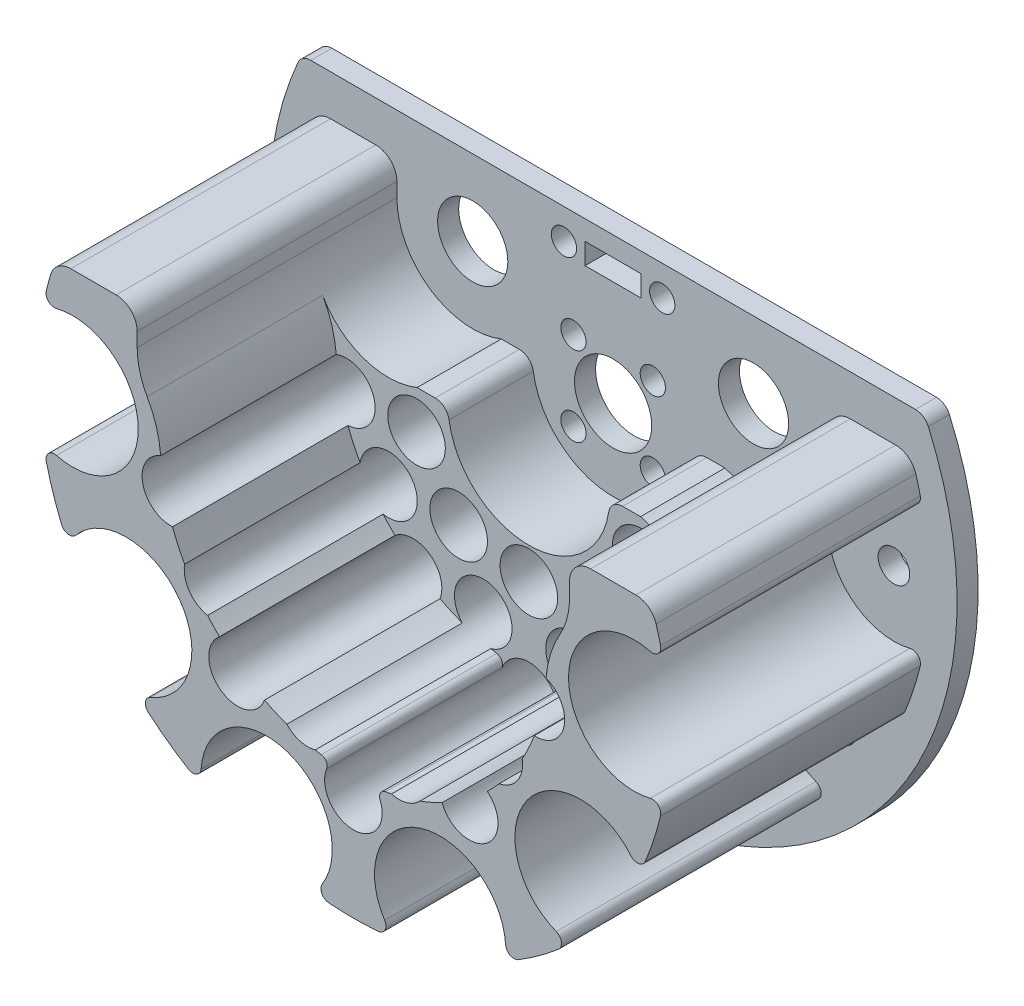
from build123d import *

# Parameters (mm, degrees)
EXTRUDE_1_DEPTH             = 25
EXTRUDE_2_DEPTH             = 12
EXTRUDE_3_DEPTH             = 3
SKETCH_4_W                  = 8
SKETCH_4_H                  = 3
CUT_EXTRUDE_1_DEPTH         = 41
SKETCH_5_W                  = 4.1
SKETCH_5_H                  = 39
SKETCH_6_W                  = 4.1
SKETCH_6_H                  = 39
SKETCH_7_W                  = 4.1
SKETCH_7_H                  = 39
SKETCH_8_W                  = 4.1
SKETCH_8_H                  = 39
SKETCH_9_W                  = 4.1
SKETCH_9_H                  = 39
SKETCH_10_W                 = 4.1
SKETCH_10_H                 = 39
HOLE_WIZARD_8_2_8_2_1_D     = 8.2
HOLE_WIZARD_8_2_8_2_1_DEPTH = 39
HOLE_WIZARD_8_2_8_2_2_D     = 8.2
HOLE_WIZARD_8_2_8_2_2_DEPTH = 14
HOLE_WIZARD_8_2_8_2_3_D     = 8.2
HOLE_WIZARD_8_2_8_2_3_DEPTH = 40
HOLE_WIZARD_4_5_4_5_1_D     = 4.5
HOLE_WIZARD_4_5_4_5_1_DEPTH = 40
HOLE_WIZARD_11_0_11_1_D     = 11
HOLE_WIZARD_11_0_11_1_DEPTH = 40
HOLE_WIZARD_10_0_10_1_D     = 10
HOLE_WIZARD_10_0_10_1_DEPTH = 40
HOLE_WIZARD_3_6_3_6_1_D     = 3.6
HOLE_WIZARD_3_6_3_6_1_DEPTH = 40
FILLET_1_R                  = 1
FILLET_2_R                  = 2
FILLET_3_R                  = 3


with BuildPart() as part:
    # 草图1 → 凸台-拉伸1 (new body)
    with BuildSketch(Plane.XY.offset(40)):
        with BuildLine():
            Line((-30.8, 160), (-30.8, 165))
            Line((-30.8, 165), (-42.426406871, 165))
            ThreePointArc((-42.426406871, 165), (-43.14973204, 162.7710855), (-43.756046661, 160.507539227))
            ThreePointArc((-43.756046661, 160.507539227), (-43.432520931, 159.373616076), (-42.294710456, 159.064039051))
            ThreePointArc((-42.294710456, 159.064039051), (-30.65, 150), (-42.294710456, 140.935960949))
            ThreePointArc((-42.294710456, 140.935960949), (-43.432520931, 140.626383924), (-43.756046661, 139.492460773))
            ThreePointArc((-43.756046661, 139.492460773), (-42.797543233, 136.094235253), (-41.575561951, 132.781618878))
            ThreePointArc((-41.575561951, 132.781618878), (-40.647320832, 132.054419431), (-39.544848012, 132.472754574))
            ThreePointArc((-39.544848012, 132.472754574), (-24.796370878, 131.984382017), (-28.889431051, 117.806831314))
            ThreePointArc((-28.889431051, 117.806831314), (-29.627974251, 116.887590023), (-29.22320876, 115.78006327))
            ThreePointArc((-29.22320876, 115.78006327), (-26.450336353, 113.594235253), (-23.514625677, 111.632534886))
            ThreePointArc((-23.514625677, 111.632534886), (-22.336225726, 111.589824616), (-21.690197707, 112.57628212))
            ThreePointArc((-21.690197707, 112.57628212), (-9.471370878, 120.850117776), (-4.449370899, 106.974397911))
            ThreePointArc((-4.449370899, 106.974397911), (-4.506548426, 105.796611284), (-3.528098373, 105.138518506))
            ThreePointArc((-3.528098373, 105.138518506), (0, 105), (3.528098373, 105.138518506))
            ThreePointArc((3.528098373, 105.138518506), (4.506548426, 105.796611284), (4.449370899, 106.974397911))
            ThreePointArc((4.449370899, 106.974397911), (9.471370878, 120.850117776), (21.690197707, 112.57628212))
            ThreePointArc((21.690197707, 112.57628212), (22.336225726, 111.589824616), (23.514625677, 111.632534886))
            ThreePointArc((23.514625677, 111.632534886), (26.450336353, 113.594235253), (29.22320876, 115.78006327))
            ThreePointArc((29.22320876, 115.78006327), (29.627974251, 116.887590023), (28.889431051, 117.806831314))
            ThreePointArc((28.889431051, 117.806831314), (24.796370878, 131.984382017), (39.544848012, 132.472754574))
            ThreePointArc((39.544848012, 132.472754574), (40.647320832, 132.054419431), (41.575561951, 132.781618878))
            ThreePointArc((41.575561951, 132.781618878), (42.797543233, 136.094235253), (43.756046661, 139.492460773))
            ThreePointArc((43.756046661, 139.492460773), (43.432520931, 140.626383924), (42.294710456, 140.935960949))
            ThreePointArc((42.294710456, 140.935960949), (30.65, 150), (42.294710456, 159.064039051))
            ThreePointArc((42.294710456, 159.064039051), (43.432520931, 159.373616076), (43.756046661, 160.507539227))
            ThreePointArc((43.756046661, 160.507539227), (43.14973204, 162.7710855), (42.426406871, 165))
            Line((42.426406871, 165), (30.8, 165))
            Line((30.8, 165), (30.8, 160))
            ThreePointArc((30.8, 160), (30.438925132, 157.230732571), (29.379844057, 154.646634192))
            ThreePointArc((29.379844057, 154.646634192), (28.022973878, 151.464418622), (27.431201542, 148.055988174))
            ThreePointArc((27.431201542, 148.055988174), (0, 122.5), (-27.431201542, 148.055988174))
            ThreePointArc((-27.431201542, 148.055988174), (-28.022973878, 151.464418622), (-29.379844057, 154.646634192))
            ThreePointArc((-29.379844057, 154.646634192), (-30.438925132, 157.230732571), (-30.8, 160))
        make_face()
    extrude(amount=-EXTRUDE_1_DEPTH)

    # 草图2 → 凸台-拉伸2 (add)
    with BuildSketch(Plane(origin=(0, 0, 15), x_dir=(-1, 0, 0), z_dir=(0, 0, -1))):
        with BuildLine():
            Line((-42.426406871, 165), (-30.8, 165))
            Line((-30.8, 165), (-30.8, 160))
            ThreePointArc((-30.8, 160), (-26.024303752, 151.036308556), (-15.920784389, 150))
            Line((-15.920784389, 150), (-11.5, 150))
            ThreePointArc((-11.5, 150), (0, 138.5), (11.5, 150))
            Line((11.5, 150), (15.920784389, 150))
            ThreePointArc((15.920784389, 150), (26.024303752, 151.036308556), (30.8, 160))
            Line((30.8, 160), (30.8, 165))
            Line((30.8, 165), (42.426406871, 165))
            ThreePointArc((42.426406871, 165), (43.14973204, 162.7710855), (43.756046661, 160.507539227))
            ThreePointArc((43.756046661, 160.507539227), (43.432520931, 159.373616076), (42.294710456, 159.064039051))
            ThreePointArc((42.294710456, 159.064039051), (30.65, 150), (42.294710456, 140.935960949))
            ThreePointArc((42.294710456, 140.935960949), (43.432520931, 140.626383924), (43.756046661, 139.492460773))
            ThreePointArc((43.756046661, 139.492460773), (42.797543233, 136.094235253), (41.575561951, 132.781618878))
            ThreePointArc((41.575561951, 132.781618878), (40.647320832, 132.054419431), (39.544848012, 132.472754574))
            ThreePointArc((39.544848012, 132.472754574), (24.796370878, 131.984382017), (28.889431051, 117.806831314))
            ThreePointArc((28.889431051, 117.806831314), (29.627974251, 116.887590023), (29.22320876, 115.78006327))
            ThreePointArc((29.22320876, 115.78006327), (26.450336353, 113.594235253), (23.514625677, 111.632534886))
            ThreePointArc((23.514625677, 111.632534886), (22.336225726, 111.589824616), (21.690197707, 112.57628212))
            ThreePointArc((21.690197707, 112.57628212), (9.471370878, 120.850117776), (4.449370899, 106.974397911))
            ThreePointArc((4.449370899, 106.974397911), (4.506548426, 105.796611284), (3.528098373, 105.138518506))
            ThreePointArc((3.528098373, 105.138518506), (0, 105), (-3.528098373, 105.138518506))
            ThreePointArc((-3.528098373, 105.138518506), (-4.506548426, 105.796611284), (-4.449370899, 106.974397911))
            ThreePointArc((-4.449370899, 106.974397911), (-9.471370878, 120.850117776), (-21.690197707, 112.57628212))
            ThreePointArc((-21.690197707, 112.57628212), (-22.336225726, 111.589824616), (-23.514625677, 111.632534886))
            ThreePointArc((-23.514625677, 111.632534886), (-26.450336353, 113.594235253), (-29.22320876, 115.78006327))
            ThreePointArc((-29.22320876, 115.78006327), (-29.627974251, 116.887590023), (-28.889431051, 117.806831314))
            ThreePointArc((-28.889431051, 117.806831314), (-24.796370878, 131.984382017), (-39.544848012, 132.472754574))
            ThreePointArc((-39.544848012, 132.472754574), (-40.647320832, 132.054419431), (-41.575561951, 132.781618878))
            ThreePointArc((-41.575561951, 132.781618878), (-42.797543233, 136.094235253), (-43.756046661, 139.492460773))
            ThreePointArc((-43.756046661, 139.492460773), (-43.432520931, 140.626383924), (-42.294710456, 140.935960949))
            ThreePointArc((-42.294710456, 140.935960949), (-30.65, 150), (-42.294710456, 159.064039051))
            ThreePointArc((-42.294710456, 159.064039051), (-43.432520931, 159.373616076), (-43.756046661, 160.507539227))
            ThreePointArc((-43.756046661, 160.507539227), (-43.14973204, 162.7710855), (-42.426406871, 165))
        make_face()
    extrude(amount=EXTRUDE_2_DEPTH)

    # 草图3 → 凸台-拉伸3 (add)
    with BuildSketch(Plane.XY.offset(3)):
        with BuildLine():
            Line((44.366203353, 170.8), (-44.366203353, 170.8))
            ThreePointArc((-44.366203353, 170.8), (0, 101), (44.366203353, 170.8))
        make_face()
    extrude(amount=-EXTRUDE_3_DEPTH)

    # 草图4 → 切除-拉伸1 (cut, through all)
    with BuildSketch(Plane(origin=(0, 0, 0), x_dir=(-1, 0, 0), z_dir=(0, 0, -1))):
        with Locations((0, 166.5)):
            Rectangle(SKETCH_4_W, SKETCH_4_H)
    extrude(amount=-CUT_EXTRUDE_1_DEPTH, mode=Mode.SUBTRACT)

    # 草图5 → 切除-旋转1 (revolve, cut)
    with BuildSketch(Plane(origin=(0, 144.5, 0), x_dir=(1, 0, 0), z_dir=(0, 1, 0))):
        with Locations((28.05, -20.5)):
            Rectangle(SKETCH_5_W, SKETCH_5_H)
    revolve(axis=Axis((26, 144.5, 1), (0, 0, 1)), mode=Mode.SUBTRACT)

    # 草图6 → 切除-旋转2 (revolve, cut)
    with BuildSketch(Plane(origin=(0, 136, 0), x_dir=(1, 0, 0), z_dir=(0, 1, 0))):
        with Locations((22.05, -20.5)):
            Rectangle(SKETCH_6_W, SKETCH_6_H)
    revolve(axis=Axis((20, 136, 1), (0, 0, 1)), mode=Mode.SUBTRACT)

    # 草图7 → 切除-旋转3 (revolve, cut)
    with BuildSketch(Plane(origin=(0, 127, 0), x_dir=(1, 0, 0), z_dir=(0, 1, 0))):
        with Locations((8.55, -20.5)):
            Rectangle(SKETCH_7_W, SKETCH_7_H)
    revolve(axis=Axis((6.5, 127, 1), (0, 0, 1)), mode=Mode.SUBTRACT)

    # 草图8 → 切除-旋转4 (revolve, cut)
    with BuildSketch(Plane(origin=(0, 127, 0), x_dir=(1, 0, 0), z_dir=(0, 1, 0))):
        with Locations((-4.45, -20.5)):
            Rectangle(SKETCH_8_W, SKETCH_8_H)
    revolve(axis=Axis((-6.5, 127, 1), (0, 0, 1)), mode=Mode.SUBTRACT)

    # 草图9 → 切除-旋转5 (revolve, cut)
    with BuildSketch(Plane(origin=(0, 136, 0), x_dir=(1, 0, 0), z_dir=(0, 1, 0))):
        with Locations((-17.95, -20.5)):
            Rectangle(SKETCH_9_W, SKETCH_9_H)
    revolve(axis=Axis((-20, 136, 1), (0, 0, 1)), mode=Mode.SUBTRACT)

    # 草图10 → 切除-旋转6 (revolve, cut)
    with BuildSketch(Plane(origin=(0, 144.5, 0), x_dir=(1, 0, 0), z_dir=(0, 1, 0))):
        with Locations((-23.95, -20.5)):
            Rectangle(SKETCH_10_W, SKETCH_10_H)
    revolve(axis=Axis((-26, 144.5, 1), (0, 0, 1)), mode=Mode.SUBTRACT)

    # Ø8.2 (8.2) 直径孔1
    with Locations(Plane.XY.offset(40)):
        with Locations((-16.5, 127), (16.5, 127)):
            Hole(HOLE_WIZARD_8_2_8_2_1_D / 2, depth=HOLE_WIZARD_8_2_8_2_1_DEPTH)

    # Ø8.2 (8.2) 直径孔2
    with Locations(Plane.XY.offset(15)):
        with Locations((0, 134), (10, 136), (16, 144.5), (-10, 136), (-16, 144.5)):
            Hole(HOLE_WIZARD_8_2_8_2_2_D / 2, depth=HOLE_WIZARD_8_2_8_2_2_DEPTH)

    # Ø8.2 (8.2) 直径孔3
    with Locations(Plane(origin=(0, 0, 0), x_dir=(-1, 0, 0), z_dir=(0, 0, -1))):
        with Locations((0, 120)):
            Hole(HOLE_WIZARD_8_2_8_2_3_D / 2, depth=HOLE_WIZARD_8_2_8_2_3_DEPTH)

    # Ø4.5 (4.5) 直径孔1
    with Locations(Plane(origin=(0, 0, 0), x_dir=(-1, 0, 0), z_dir=(0, 0, -1))):
        with Locations((-40, 150), (-32.360679775, 126.488589908), (-12.360679775, 111.957739348), (12.360679775, 111.957739348), (32.360679775, 126.488589908), (40, 150)):
            Hole(HOLE_WIZARD_4_5_4_5_1_D / 2, depth=HOLE_WIZARD_4_5_4_5_1_DEPTH)

    # Ø11.0 (11) 直径孔1
    with Locations(Plane(origin=(0, 0, 0), x_dir=(-1, 0, 0), z_dir=(0, 0, -1))):
        with Locations((0, 150)):
            Hole(HOLE_WIZARD_11_0_11_1_D / 2, depth=HOLE_WIZARD_11_0_11_1_DEPTH)

    # Ø10.0 (10) 直径孔1
    with Locations(Plane(origin=(0, 0, 0), x_dir=(-1, 0, 0), z_dir=(0, 0, -1))):
        with Locations((20, 160), (-20, 160)):
            Hole(HOLE_WIZARD_10_0_10_1_D / 2, depth=HOLE_WIZARD_10_0_10_1_DEPTH)

    # Ø3.6 (3.6) 直径孔1
    with Locations(Plane(origin=(0, 0, 0), x_dir=(-1, 0, 0), z_dir=(0, 0, -1))):
        with Locations((5.656854249, 155.656854249), (-7, 166.5), (7, 166.5), (5.656854249, 144.343145751), (-5.656854249, 144.343145751), (-5.656854249, 155.656854249)):
            Hole(HOLE_WIZARD_3_6_3_6_1_D / 2, depth=HOLE_WIZARD_3_6_3_6_1_DEPTH)

    # 圆角1
    fillet_1_edges = [part.edges().sort_by_distance(p)[0] for p in [
        (3.106287817, 122.676, 27.5),
        (-3.106287817, 122.676, 27.5),
    ]]
    fillet(fillet_1_edges, radius=FILLET_1_R)

    # 圆角2
    fillet_2_edges = [part.edges().sort_by_distance(p)[0] for p in [
        (-11.5, 150, 9),
        (11.5, 150, 9),
        (44.366203353, 170.8, 1.5),
        (-44.366203353, 170.8, 1.5),
    ]]
    fillet(fillet_2_edges, radius=FILLET_2_R)

    # 圆角3
    fillet_3_edges = [part.edges().sort_by_distance(p)[0] for p in [
        (30.8, 165, 21.5),
        (42.426406871, 165, 21.5),
        (-42.426406871, 165, 21.5),
        (-30.8, 165, 21.5),
    ]]
    fillet(fillet_3_edges, radius=FILLET_3_R)


solid = part.part
